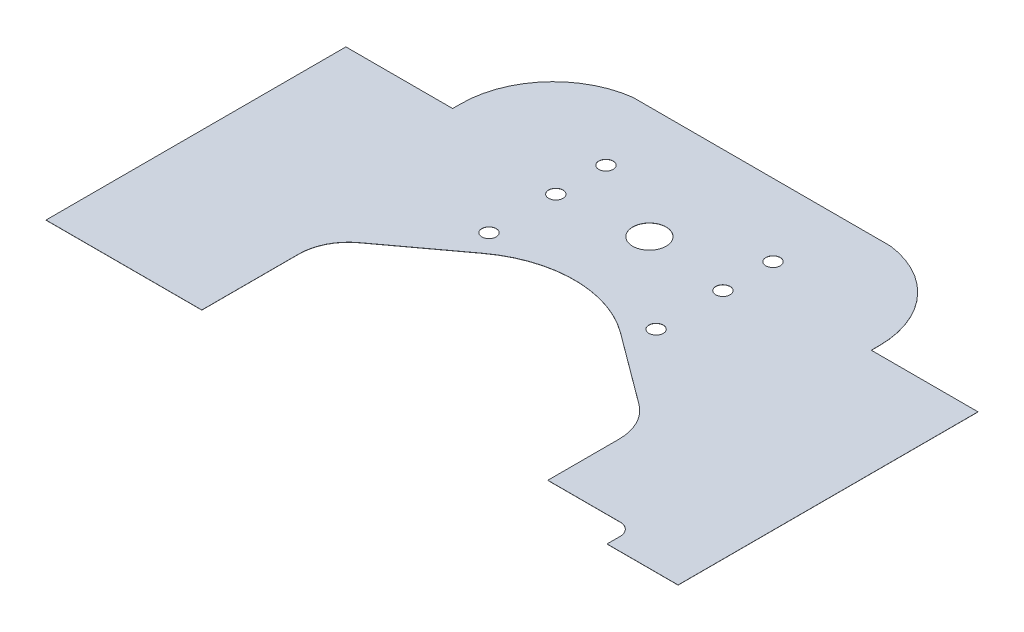
from build123d import *

# Parameters (mm, degrees)
SKETCH1_R           = 1.37
SKETCH1_R_2         = 3.175
BOSS_EXTRUDE1_DEPTH = 0.0254
CUT_EXTRUDE1_DEPTH  = 1.0254


with BuildPart() as part:
    # Sketch1 → Boss-Extrude1 (new body)
    with BuildSketch(Plane(origin=(0, 0, 0), x_dir=(1, 0, 0), z_dir=(0, 1, 0))):
        with BuildLine():
            Line((46.055581216, -52.102523804), (46.055581216, -55.105805187))
            Line((46.055581216, -55.105805187), (60.06, -55.105805187))
            Line((60.06, -55.105805187), (60.06, 2.3825))
            Line((60.06, 2.3825), (39.775, 2.3825))
            Line((39.775, 2.3825), (39.775, 3.9425))
            ThreePointArc((39.775, 3.9425), (35.406414292, 15.5292518), (24.475533644, 21.347602652))
            Line((24.475533644, 21.347602652), (-24.475533644, 21.347602652))
            ThreePointArc((-24.475533644, 21.347602652), (-35.406414292, 15.5292518), (-39.775, 3.9425))
            Line((-39.775, 3.9425), (-39.775, 2.3825))
            Line((-39.775, 2.3825), (-60.06, 2.3825))
            Line((-60.06, 2.3825), (-60.06, -55.105805187))
            Line((-60.06, -55.105805187), (-29.948964567, -55.105805187))
            Line((-29.948964567, -55.105805187), (-29.948964567, -36.195))
            ThreePointArc((-29.948964567, -36.195), (-28.992277356, -32.169149844), (-26.326764623, -29.004065049))
            Line((-26.326764623, -29.004065049), (-12.767240814, -18.959697769))
            ThreePointArc((-12.767240814, -18.959697769), (0, -14.746035433), (12.767240814, -18.959697769))
            Line((12.767240814, -18.959697769), (26.326764623, -29.004065049))
            ThreePointArc((26.326764623, -29.004065049), (28.992277356, -32.169149844), (29.948964567, -36.195))
            Line((29.948964567, -36.195), (29.948964567, -50.252557813))
            Line((29.948964567, -50.252557813), (44.205615226, -50.252557813))
            ThreePointArc((44.205615226, -50.252557813), (45.513738722, -50.794400307), (46.055581216, -52.102523804))
        make_face()
        with Locations(Location((-15.875, -1.905, 0), (0, 0, 270))):  # turned: the seam where the file's is
            Circle(SKETCH1_R, mode=Mode.SUBTRACT)
        with Locations(Location((-15.875, 7.62, 0), (0, 0, 270))):  # turned: the seam where the file's is
            Circle(SKETCH1_R, mode=Mode.SUBTRACT)
        with Locations(Location((-15.875, -14.605, 0), (0, 0, 270))):  # turned: the seam where the file's is
            Circle(SKETCH1_R, mode=Mode.SUBTRACT)
        with Locations(Location((0, 0, 0), (0, 0, 270))):  # turned: the seam where the file's is
            Circle(SKETCH1_R_2, mode=Mode.SUBTRACT)
        with Locations(Location((15.875, -1.905, 0), (0, 0, 270))):  # turned: the seam where the file's is
            Circle(SKETCH1_R, mode=Mode.SUBTRACT)
        with Locations(Location((15.875, 7.62, 0), (0, 0, 270))):  # turned: the seam where the file's is
            Circle(SKETCH1_R, mode=Mode.SUBTRACT)
        with Locations(Location((15.875, -14.605, 0), (0, 0, 270))):  # turned: the seam where the file's is
            Circle(SKETCH1_R, mode=Mode.SUBTRACT)
    extrude(amount=BOSS_EXTRUDE1_DEPTH)

    # Sketch2 → Cut-Extrude1 (cut, through all)
    with BuildSketch(Plane(origin=(0, 0.0254, 0), x_dir=(1, 0, 0), z_dir=(0, 1, 0))):
        with BuildLine():
            Line((-60.06, -55.105805187), (-29.948964567, -55.105805187))
            Line((-29.948964567, -55.105805187), (-29.948964567, -36.195))
            ThreePointArc((-29.948964567, -36.195), (-28.992277356, -32.169149844), (-26.326764623, -29.004065049))
            Line((-26.326764623, -29.004065049), (-12.767240814, -18.959697769))
            ThreePointArc((-12.767240814, -18.959697769), (0, -14.746035433), (12.767240814, -18.959697769))
            Line((12.767240814, -18.959697769), (26.326764623, -29.004065049))
            ThreePointArc((26.326764623, -29.004065049), (28.992277356, -32.169149844), (29.948964567, -36.195))
            Line((29.948964567, -36.195), (29.948964567, -50.252557813))
            Line((29.948964567, -50.252557813), (44.205615226, -50.252557813))
            ThreePointArc((44.205615226, -50.252557813), (45.513738722, -50.794400307), (46.055581216, -52.102523804))
            Line((46.055581216, -52.102523804), (46.055581216, -55.105805187))
            Line((46.055581216, -55.105805187), (60.06, -55.105805187))
            Line((60.06, -55.105805187), (60.06, -54.605805187))
            Line((60.06, -54.605805187), (46.555581216, -54.605805187))
            Line((46.555581216, -54.605805187), (46.555581216, -52.102523804))
            ThreePointArc((46.555581216, -52.102523804), (45.867292113, -50.440846916), (44.205615226, -49.752557813))
            Line((44.205615226, -49.752557813), (30.448964567, -49.752557813))
            Line((30.448964567, -49.752557813), (30.448964567, -36.195))
            ThreePointArc((30.448964567, -36.195), (29.43882496, -31.944215992), (26.624383671, -28.602290358))
            Line((26.624383671, -28.602290358), (13.064859861, -18.557923078))
            ThreePointArc((13.064859861, -18.557923078), (0, -14.246035433), (-13.064859861, -18.557923078))
            Line((-13.064859861, -18.557923078), (-26.624383671, -28.602290358))
            ThreePointArc((-26.624383671, -28.602290358), (-29.43882496, -31.944215992), (-30.448964567, -36.195))
            Line((-30.448964567, -36.195), (-30.448964567, -54.605805187))
            Line((-30.448964567, -54.605805187), (-60.06, -54.605805187))
            Line((-60.06, -54.605805187), (-60.06, -55.105805187))
        make_face()
    extrude(amount=-CUT_EXTRUDE1_DEPTH, mode=Mode.SUBTRACT)


solid = part.part
